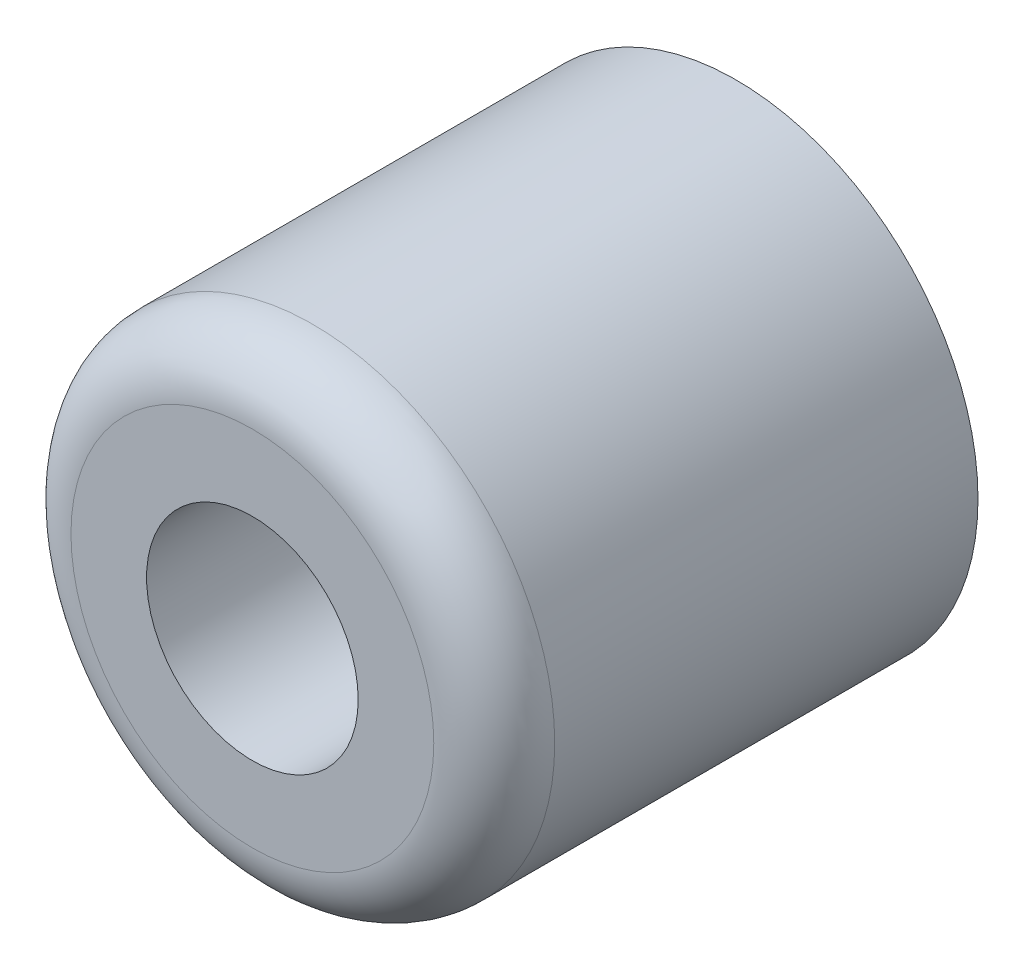
from build123d import *

# Parameters (mm, degrees)
SKETCH1_R           = 12.7
SKETCH1_R_2         = 3.571875
BOSS_EXTRUDE1_DEPTH = 25.4
SKETCH2_R           = 5.55625
CUT_EXTRUDE1_DEPTH  = 12.7
FILLET1_R           = 3.175


with BuildPart() as part:
    # Sketch1 → Boss-Extrude1 (new body)
    with BuildSketch(Plane.XY):
        Circle(SKETCH1_R)
        Circle(SKETCH1_R_2, mode=Mode.SUBTRACT)
    extrude(amount=BOSS_EXTRUDE1_DEPTH)

    # Sketch2 → Cut-Extrude1 (cut)
    with BuildSketch(Plane.XY.offset(25.4)):
        Circle(SKETCH2_R)
    extrude(amount=-CUT_EXTRUDE1_DEPTH, mode=Mode.SUBTRACT)

    # Fillet1
    fillet1_edges = [part.edges().sort_by_distance(p)[0] for p in [
        (-12.7, 0, 25.4),
    ]]
    fillet(fillet1_edges, radius=FILLET1_R)


solid = part.part
